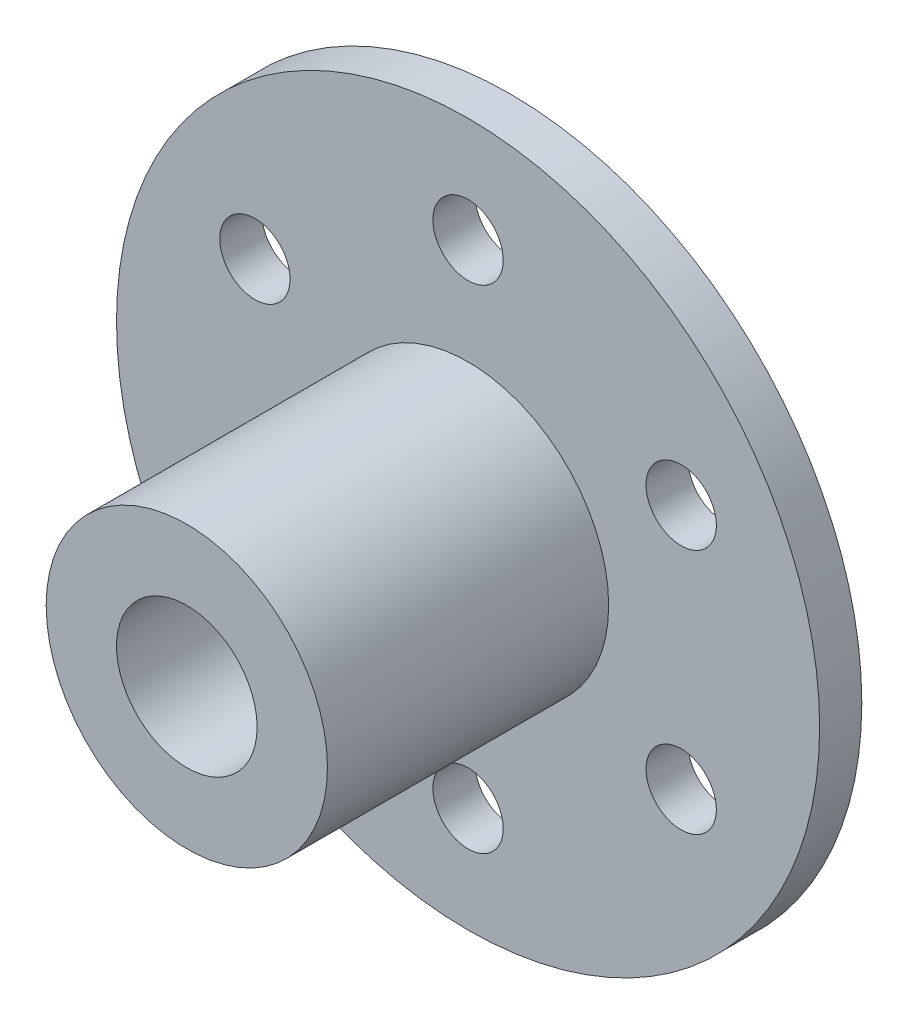
from build123d import *

# Parameters (mm, degrees)
SKETCH1_R           = 50
SKETCH1_R_2         = 10
BOSS_EXTRUDE1_DEPTH = 6
SKETCH1_3_R         = 20
SKETCH1_3_R_2       = 10
BOSS_EXTRUDE2_DEPTH = 40
SKETCH1_4_R         = 5
CUT_EXTRUDE1_DEPTH  = 82.240384046
CIRPATTERN1_COUNT   = 6


with BuildPart() as part:
    # Sketch1 → Boss-Extrude1 (new body)
    with BuildSketch(Plane.XY):
        Circle(SKETCH1_R)
        Circle(SKETCH1_R_2, mode=Mode.SUBTRACT)
    extrude(amount=-BOSS_EXTRUDE1_DEPTH)

    # Sketch1_4 → Cut-Extrude1 (cut, through all)
    with BuildSketch(Plane.XY):
        with Locations((0, 35)):
            Circle(SKETCH1_4_R)
    cut_extrude1 = extrude(amount=-CUT_EXTRUDE1_DEPTH, mode=Mode.SUBTRACT)

    # CirPattern1: Cut-Extrude1 ×6 about axis
    cirpattern1_axis = Axis((0, 0, 40), (0, 0, -1))
    for i in range(1, CIRPATTERN1_COUNT):
        add(cut_extrude1.rotate(cirpattern1_axis, i * 360 / CIRPATTERN1_COUNT), mode=Mode.SUBTRACT)


with BuildPart() as body_2:
    # Sketch1_3 → Boss-Extrude2 (new body)
    with BuildSketch(Plane.XY):
        Circle(SKETCH1_3_R)
        Circle(SKETCH1_3_R_2, mode=Mode.SUBTRACT)
    extrude(amount=BOSS_EXTRUDE2_DEPTH)


solid = Compound([part.part, body_2.part])
